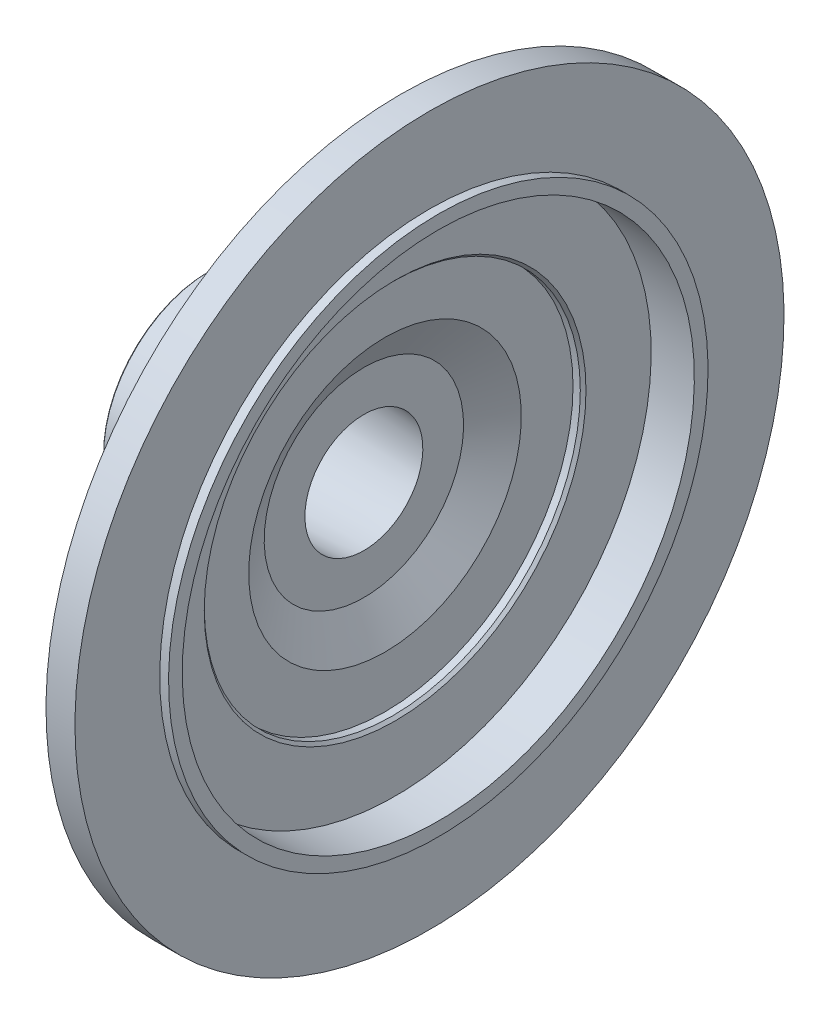
from build123d import *


with BuildPart() as part:
    # Эскиз1 → Повернуть1 (revolve)
    with BuildSketch(Plane.XY):
        with BuildLine():
            Line((-88.367595483, 25.597236847), (-88.367595483, 36.95))
            Line((-88.367595483, 36.95), (-87.867595483, 37.45))
            Line((-87.867595483, 37.45), (-48.067595483, 37.45))
            ThreePointArc((-48.067595483, 37.45), (-44.532061577, 38.914466094), (-43.067595483, 42.45))
            Line((-43.067595483, 42.45), (-43.067595483, 68.6))
            Line((-43.067595483, 68.6), (-35.767595483, 68.6))
            Line((-35.767595483, 68.6), (-35.767595483, 95.25))
            Line((-35.767595483, 95.25), (-25.917595483, 105.1))
            Line((-25.917595483, 105.1), (-20.767595483, 105.1))
            Line((-20.767595483, 105.1), (-20.767595483, 124.82))
            Line((-20.767595483, 124.82), (-10.567595483, 124.82))
            Line((-10.567595483, 124.82), (-10.567595483, 94.97))
            Line((-10.567595483, 94.97), (-7.467595483, 94.97))
            Line((-7.467595483, 94.97), (-7.467595483, 90.15))
            Line((-7.467595483, 90.15), (-22.667595483, 90.15))
            Line((-22.667595483, 90.15), (-22.667595483, 67.2))
            Line((-22.667595483, 67.2), (-23.667595483, 66.2))
            Line((-23.667595483, 66.2), (-26.227595483, 66.2))
            Line((-26.227595483, 66.2), (-26.227595483, 47.99))
            Line((-26.227595483, 47.99), (-33.667595483, 35.103541992))
            Line((-33.667595483, 35.103541992), (-33.667595483, 20.76))
            Line((-33.667595483, 20.76), (-86.870219917, 23.911307188))
            Line((-86.870219917, 23.911307188), (-88.367595483, 25.597236847))
        make_face()
    revolve(axis=Axis((0, 0, 0), (-1, 0, 0)))


solid = part.part
